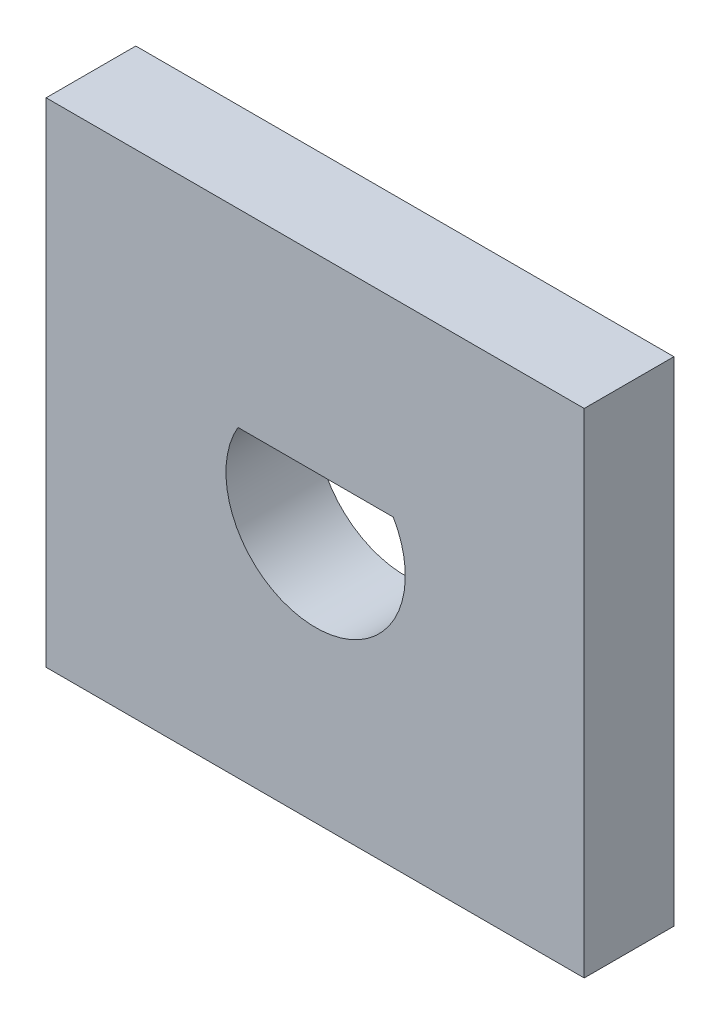
from build123d import *

# Parameters (mm, degrees)
SKETCH_1_W          = 12
SKETCH_1_H          = 11
EXTRUDE_1_DEPTH     = 2
CUT_EXTRUDE_2_DEPTH = 2


with BuildPart() as part:
    # 草图1 → 凸台-拉伸1 (new body)
    with BuildSketch(Plane.XY):
        with Locations((-0.010267275, -0.272881356)):
            Rectangle(SKETCH_1_W, SKETCH_1_H)
    extrude(amount=EXTRUDE_1_DEPTH)

    # 草图2 → 切除-拉伸2 (cut)
    with BuildSketch(Plane.XY.offset(2)):
        with BuildLine():
            Line((0, 1), (-1.732050808, 1))
            ThreePointArc((-1.732050808, 1), (-0.51763809, -1.931851653), (2, 0))
            ThreePointArc((2, 0), (1.931851653, 0.51763809), (1.732050808, 1))
            Line((1.732050808, 1), (0, 1))
        make_face()
    extrude(amount=-CUT_EXTRUDE_2_DEPTH, mode=Mode.SUBTRACT)


solid = part.part
